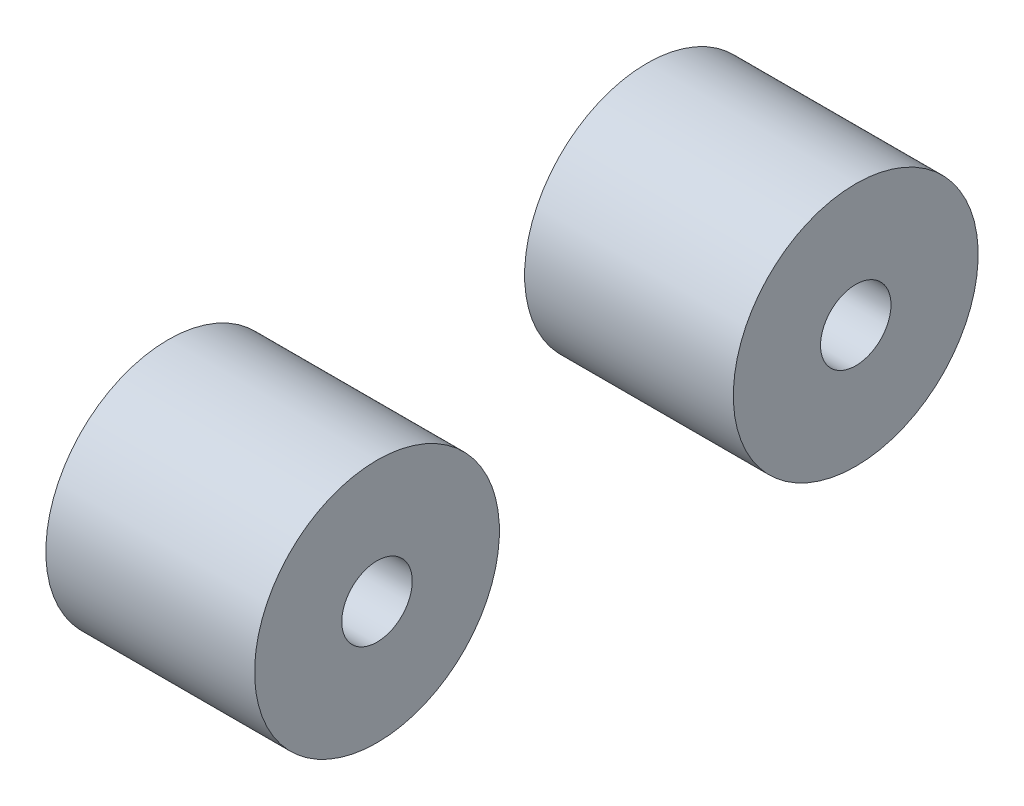
from build123d import *

# Parameters (mm, degrees)
SKETCH1_W          = 22
SKETCH1_H          = 12.9
SKETCH2_R          = 3.71375
CUT_EXTRUDE1_DEPTH = 7.5725
SKETCH4_R          = 3.71375
CUT_EXTRUDE2_DEPTH = 7.0725


with BuildPart() as part:
    # Sketch1 → Revolve1 (revolve)
    with BuildSketch(Plane.XY):
        with Locations((19.255, 6.45)):
            Rectangle(SKETCH1_W, SKETCH1_H)
    revolve(axis=Axis((8.255, 0, 0), (1, 0, 0)))

    # Sketch2 → Cut-Extrude1 (cut)
    with BuildSketch(Plane.ZY.offset(-8.255)):
        Circle(SKETCH2_R)
    extrude(amount=-CUT_EXTRUDE1_DEPTH, mode=Mode.SUBTRACT)

    # Sketch4 → Cut-Extrude2 (cut)
    with BuildSketch(Plane(origin=(30.255, 0, 0), x_dir=(0, 0, -1), z_dir=(1, 0, 0))):
        Circle(SKETCH4_R)
    extrude(amount=-CUT_EXTRUDE2_DEPTH, mode=Mode.SUBTRACT)


with BuildPart() as body_2:
    # Body-Move/Copy1: copy of part
    add(part.part.moved(Location((0, 0, 50.452769062))))


solid = Compound([part.part, body_2.part])
